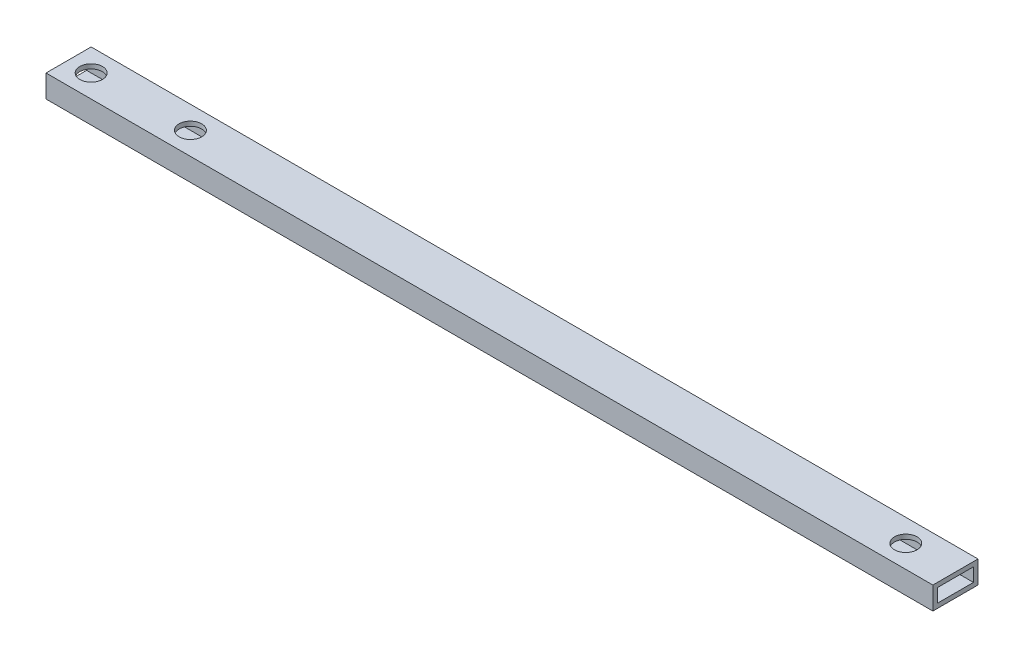
from build123d import *

# Parameters (mm, degrees)
CROQUIS1_W              = 10
CROQUIS1_H              = 5
CROQUIS1_W_2            = 8
CROQUIS1_H_2            = 3
SALIENTE_EXTRUIR1_DEPTH = 393
CROQUIS2_R              = 2.5
CORTAR_EXTRUIR1_DEPTH   = 5
SKETCH1_W               = 196.5
SKETCH1_H               = 5
CUT_EXTRUDE1_DEPTH      = 10


with BuildPart() as part:
    # Croquis1 → Saliente-Extruir1 (new body)
    with BuildSketch(Plane(origin=(0, 0, 0), x_dir=(0, 0, -1), z_dir=(1, 0, 0))):
        Rectangle(CROQUIS1_W, CROQUIS1_H)
        Rectangle(CROQUIS1_W_2, CROQUIS1_H_2, mode=Mode.SUBTRACT)
    extrude(amount=SALIENTE_EXTRUIR1_DEPTH)

    # Croquis2 → Cortar-Extruir1 (cut)
    with BuildSketch(Plane(origin=(0, 2.5, 0), x_dir=(1, 0, 0), z_dir=(0, 1, 0))):
        with Locations((5, 0)):
            Circle(CROQUIS2_R)
        with Locations((388, 0)):
            Circle(CROQUIS2_R)
        with Locations((27, 0)):
            Circle(CROQUIS2_R)
        with Locations((366, 0)):
            Circle(CROQUIS2_R)
        with Locations((207.5, 0)):
            Circle(CROQUIS2_R)
        with Locations((185.5, 0)):
            Circle(CROQUIS2_R)
    extrude(amount=-CORTAR_EXTRUIR1_DEPTH, mode=Mode.SUBTRACT)

    # Sketch1 → Cut-Extrude1 (cut)
    with BuildSketch(Plane.XY.offset(5)):
        with Locations((294.75, 0)):
            Rectangle(SKETCH1_W, SKETCH1_H)
    extrude(amount=-CUT_EXTRUDE1_DEPTH, mode=Mode.SUBTRACT)


solid = part.part
